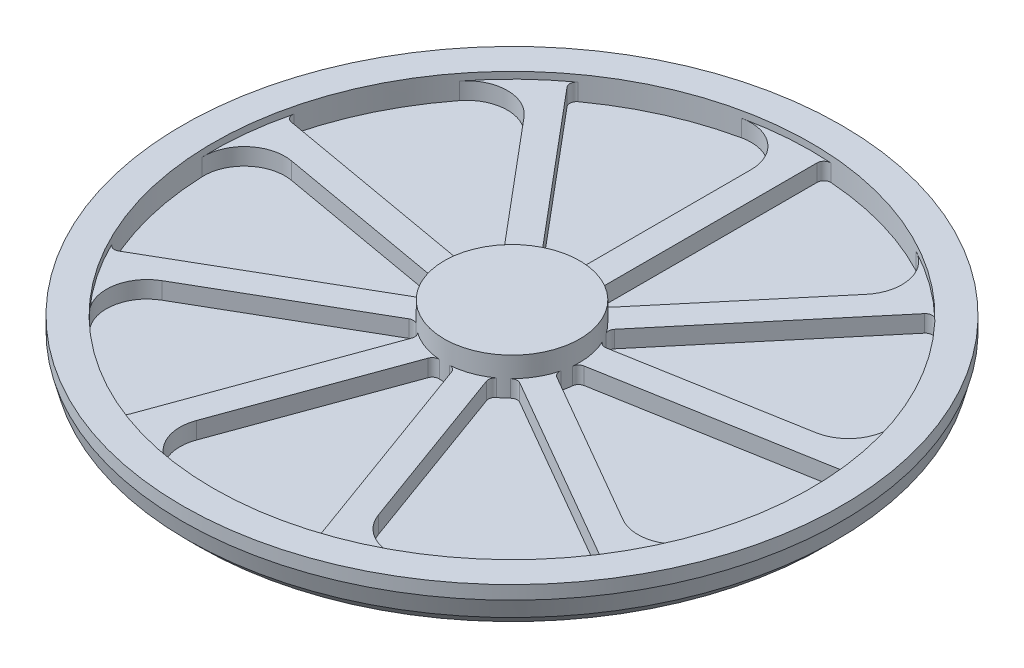
from build123d import *

# Parameters (mm, degrees)
SKETCH1_R           = 486.25
BOSS_EXTRUDE1_DEPTH = 65
SKETCH3_R           = 441.25
CUT_EXTRUDE1_DEPTH  = 35
SKETCH6_R           = 100
BOSS_EXTRUDE3_DEPTH = 55
BOSS_EXTRUDE4_DEPTH = 25
CIRPATTERN1_COUNT   = 9


with BuildPart() as part:
    # Sketch1 → Boss-Extrude1 (new body)
    with BuildSketch(Plane(origin=(0, 0, 0), x_dir=(1, 0, 0), z_dir=(0, 1, 0))):
        Circle(SKETCH1_R)
    extrude(amount=BOSS_EXTRUDE1_DEPTH)

    # Sketch3 → Cut-Extrude1 (cut)
    with BuildSketch(Plane(origin=(0, 65, 0), x_dir=(1, 0, 0), z_dir=(0, 1, 0))):
        Circle(SKETCH3_R)
    extrude(amount=-CUT_EXTRUDE1_DEPTH, mode=Mode.SUBTRACT)

    # Sketch5 → Cut-Revolve1 (revolve, cut)
    with BuildSketch(Plane(origin=(0, 0, 0), x_dir=(0, 0, -1), z_dir=(1, 0, 0))):
        Polygon((486.25, 45), (478.929491924, 17.679491924), (461.25, 0), (486.25, 0), align=None)
    revolve(axis=Axis((0, 89.25, 0), (0, -1, 0)), mode=Mode.SUBTRACT)

    # Sketch6 → Boss-Extrude3 (add)
    with BuildSketch(Plane(origin=(0, 30, 0), x_dir=(1, 0, 0), z_dir=(0, 1, 0))):
        Circle(SKETCH6_R)
    extrude(amount=BOSS_EXTRUDE3_DEPTH)

    # Sketch7 → Boss-Extrude4 (add)
    with BuildSketch(Plane(origin=(0, 30, 0), x_dir=(1, 0, 0), z_dir=(0, 1, 0))):
        with BuildLine():
            Line((0, 441.25), (0, 100))
            ThreePointArc((0, 100), (13.767464211, 99.047750753), (27.272727273, 96.209138584))
            ThreePointArc((27.272727273, 96.209138584), (22.022759648, 99.799825551), (20, 105.830052443))
            Line((20, 105.830052443), (20, 430.205256244))
            ThreePointArc((20, 430.205256244), (23.179315347, 437.518139456), (30.695652174, 440.181030302))
            ThreePointArc((30.695652174, 440.181030302), (15.357129929, 440.982676599), (0, 441.25))
        make_face()
        with BuildLine():
            Line((-20, 372.762072239), (-20, 105.830052443))
            ThreePointArc((-20, 105.830052443), (-22.022759648, 99.799825551), (-27.272727273, 96.209138584))
            ThreePointArc((-27.272727273, 96.209138584), (-13.767464211, 99.047750753), (0, 100))
            Line((0, 100), (0, 441.25))
            ThreePointArc((0, 441.25), (-46.554925044, 438.787193813), (-92.590163934, 431.426267214))
            ThreePointArc((-92.590163934, 431.426267214), (-42.286672356, 419.427958259), (-20, 372.762072239))
        make_face()
    boss_extrude4 = extrude(amount=BOSS_EXTRUDE4_DEPTH)

    # CirPattern1: Boss-Extrude4 ×9 about axis
    cirpattern1_axis = Axis((0, 0, 0), (0, 1, 0))
    for i in range(1, CIRPATTERN1_COUNT):
        add(boss_extrude4.rotate(cirpattern1_axis, i * 360 / CIRPATTERN1_COUNT))


solid = part.part
